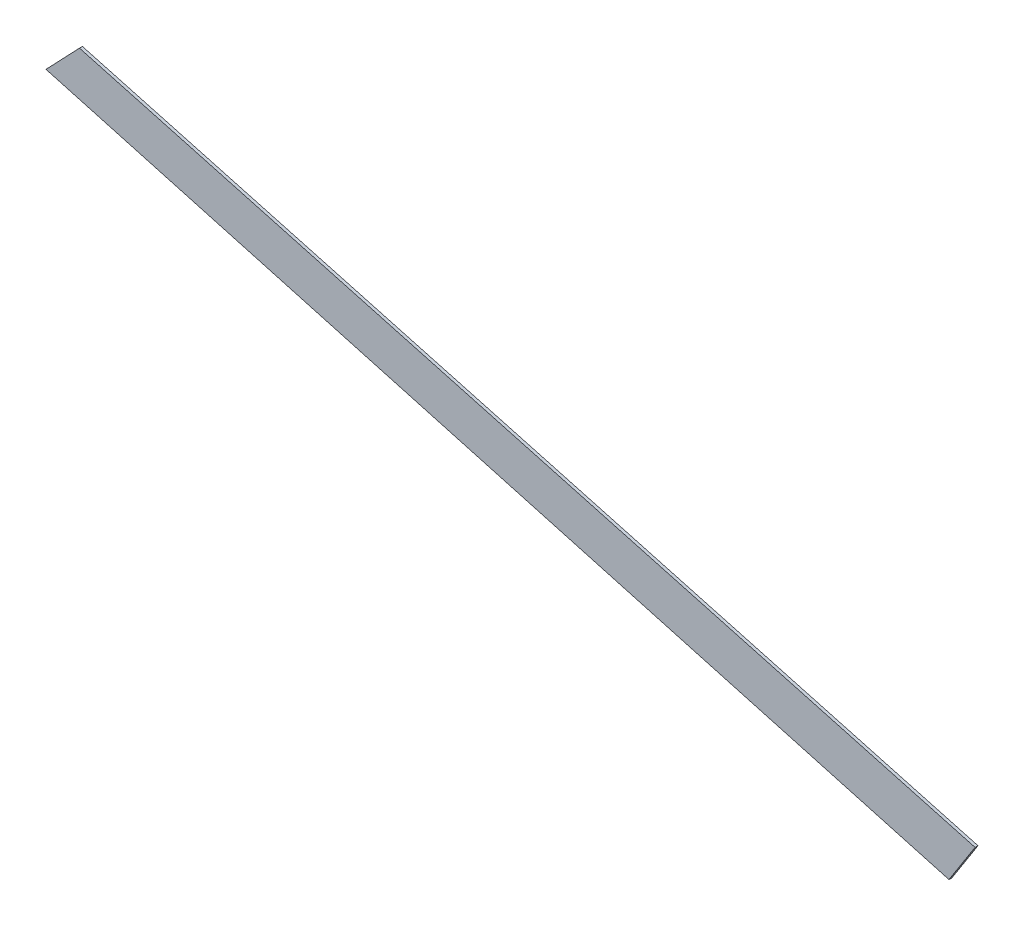
from build123d import *

# Parameters (mm, degrees)
BOSS_EXTRUDE1_DEPTH = 3


with BuildPart() as part:
    # 3DSketch1 → Boss-Extrude1 (new body)
    with BuildSketch(Plane(origin=(0, 0, 0), x_dir=(-0.9755629396189583, 0.21972016485069545, 0), z_dir=(0, 0, 1))):
        Polygon((0, 0), (955.238334723, -42.888097271), (980.940690888, 0), (16.976149555, 47.029887798), align=None)
    extrude(amount=BOSS_EXTRUDE1_DEPTH)


solid = part.part
